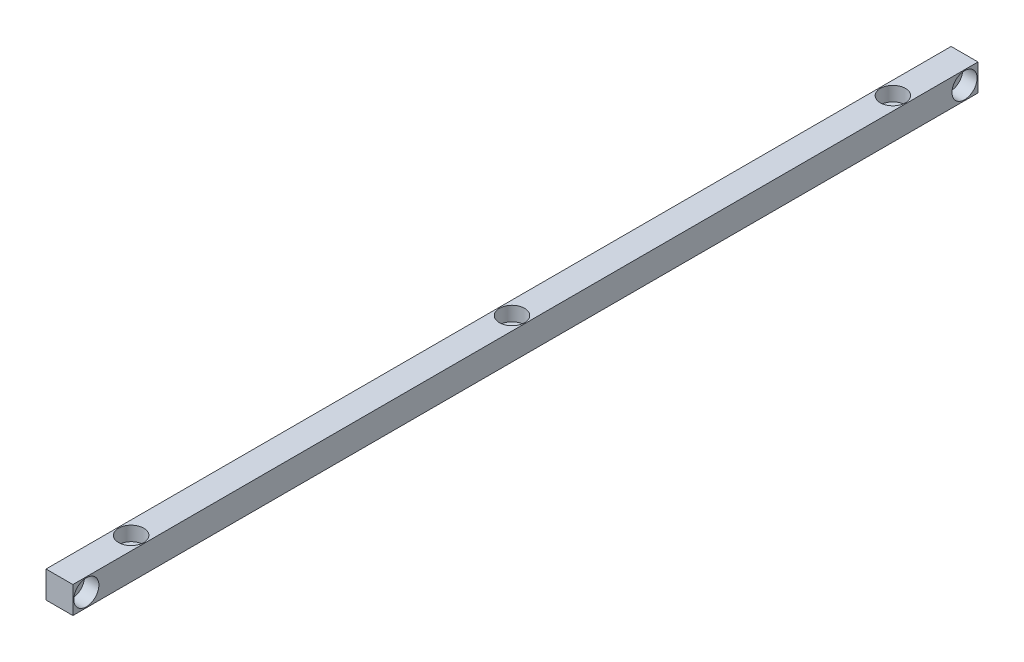
from build123d import *

# Parameters (mm, degrees)
IZIM1_W                     = 15
IZIM1_H                     = 15
Y_KSEKLIK_EKSTR_ZYON1_DEPTH = 252.5
DELIK2_D                    = 8.5
DELIK2_DEPTH                = 15
DELIK2_CBORE_D              = 14
DELIK2_CBORE_DEPTH          = 8
DELIK3_D                    = 8.5
DELIK3_DEPTH                = 15
DELIK3_CBORE_D              = 14
DELIK3_CBORE_DEPTH          = 8
L_O_ALTMA1_COUNT            = 3
L_O_ALTMA1_PITCH            = 212.5


with BuildPart() as part:
    # Çizim1 → Yükseklik-Ekstrüzyon1 (new body, symmetric)
    with BuildSketch(Plane.XY):
        Rectangle(IZIM1_W, IZIM1_H)
    extrude(amount=Y_KSEKLIK_EKSTR_ZYON1_DEPTH, both=True)

    # Delik2
    with Locations(Plane(origin=(7.5, 0, 0), x_dir=(0, 0, -1), z_dir=(1, 0, 0))):
        with Locations((245, 0)):
            delik2 = CounterBoreHole(DELIK2_D / 2, DELIK2_CBORE_D / 2, DELIK2_CBORE_DEPTH, depth=DELIK2_DEPTH)

    # Aynalama1: Delik2 across plane
    add(delik2.mirror(Plane.XY), mode=Mode.SUBTRACT)

    # Delik3
    with Locations(Plane(origin=(0, 7.5, 0), x_dir=(1, 0, 0), z_dir=(0, 1, 0))):
        with Locations((0, -212.5)):
            delik3 = CounterBoreHole(DELIK3_D / 2, DELIK3_CBORE_D / 2, DELIK3_CBORE_DEPTH, depth=DELIK3_DEPTH)

    # LÇoğaltma1: Delik3 ×3
    with Locations(*[(0, 0, -i * L_O_ALTMA1_PITCH) for i in range(1, L_O_ALTMA1_COUNT)]):
        add(delik3, mode=Mode.SUBTRACT)


solid = part.part
